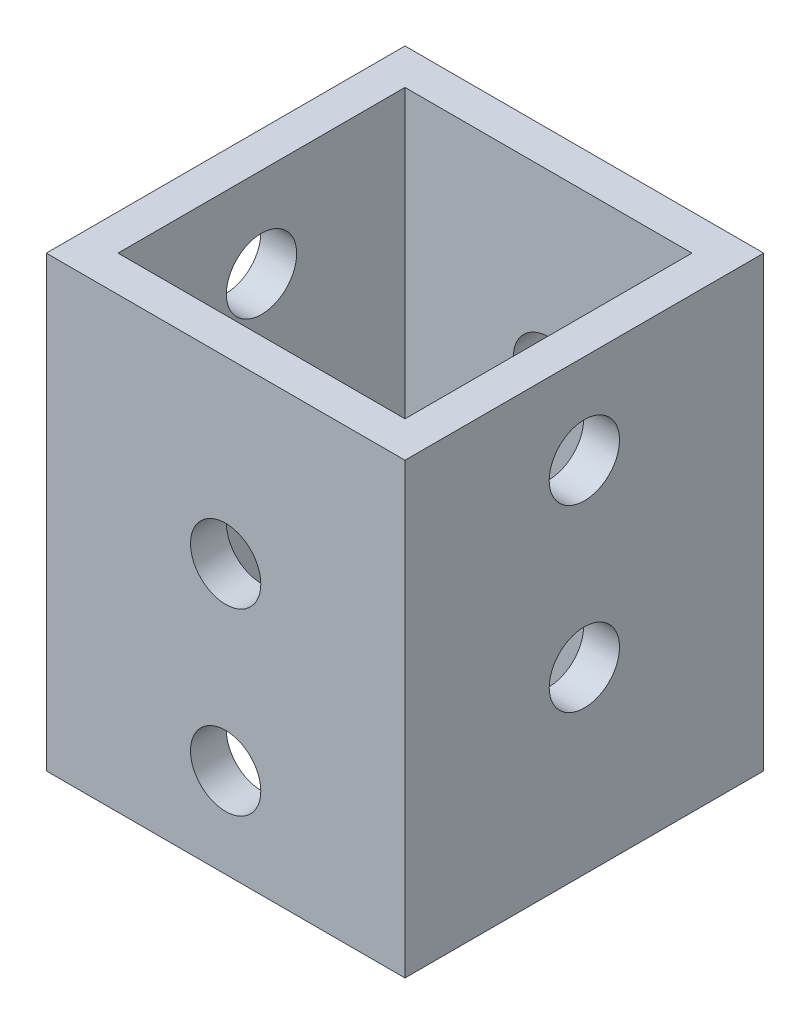
from build123d import *

# Parameters (mm, degrees)
SKETCH1_W           = 25.4
SKETCH1_H           = 25.4
SKETCH1_W_2         = 20.32
SKETCH1_H_2         = 20.32
EXTRUDE_THIN1_DEPTH = 31.75
SKETCH2_R           = 2.4892
CUT_EXTRUDE1_DEPTH  = 26.4
SKETCH3_R           = 2.4892
CUT_EXTRUDE2_DEPTH  = 26.4


with BuildPart() as part:
    # Sketch1 → Extrude-Thin1 (new body)
    with BuildSketch(Plane(origin=(0, 0, 0), x_dir=(1, 0, 0), z_dir=(0, 1, 0))):
        with Locations((12.7, 12.7)):
            Rectangle(SKETCH1_W, SKETCH1_H)
        with Locations((12.7, 12.7)):
            Rectangle(SKETCH1_W_2, SKETCH1_H_2, mode=Mode.SUBTRACT)
    extrude(amount=EXTRUDE_THIN1_DEPTH)

    # Sketch2 → Cut-Extrude1 (cut, through all)
    with BuildSketch(Plane.XY):
        with Locations((12.7, 19.05)):
            Circle(SKETCH2_R)
        with Locations((12.7, 6.35)):
            Circle(SKETCH2_R)
    extrude(amount=-CUT_EXTRUDE1_DEPTH, mode=Mode.SUBTRACT)

    # Sketch3 → Cut-Extrude2 (cut, through all)
    with BuildSketch(Plane.ZY):
        with Locations((-12.7, 25.4)):
            Circle(SKETCH3_R)
        with Locations((-12.7, 12.7)):
            Circle(SKETCH3_R)
    extrude(amount=-CUT_EXTRUDE2_DEPTH, mode=Mode.SUBTRACT)


solid = part.part
